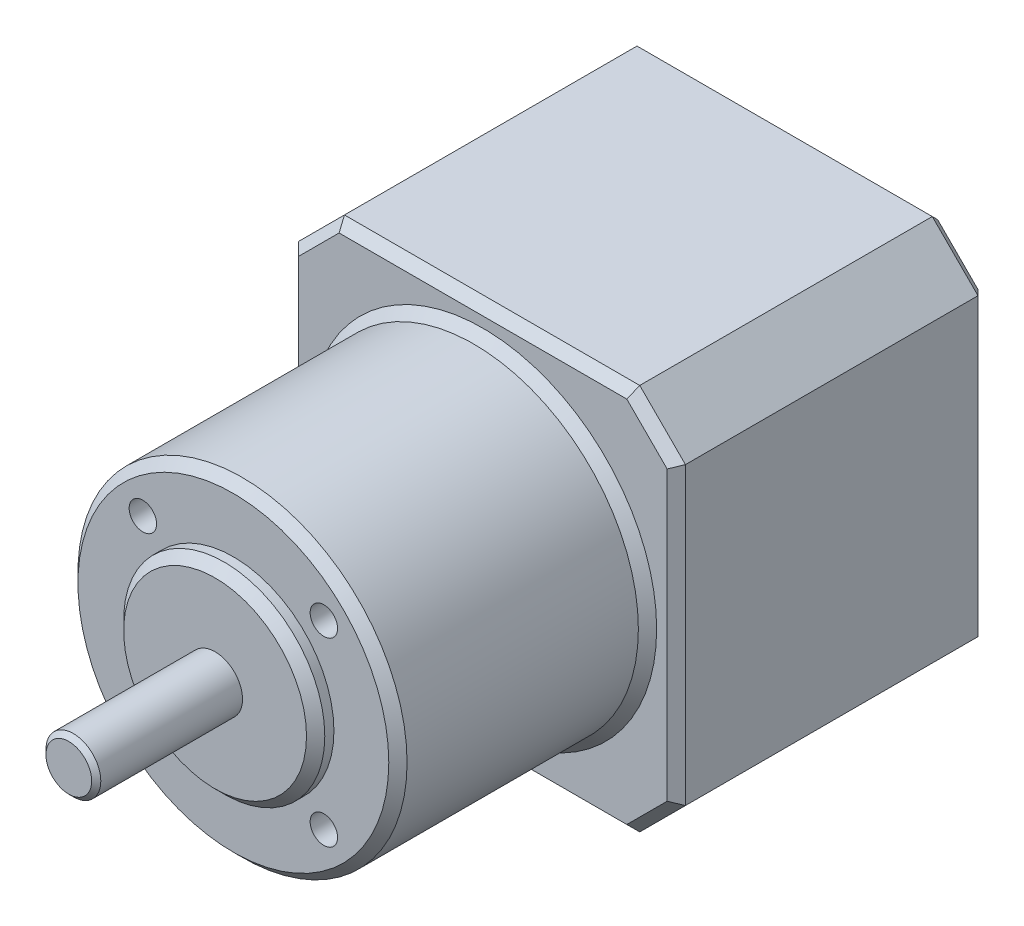
from build123d import *

# Parameters (mm, degrees)
SKETCH1_W           = 42.3
SKETCH1_H           = 42.3
BOSS_EXTRUDE1_DEPTH = 34
CHAMFER1_SIZE       = 5
SKETCH2_R           = 18
BOSS_EXTRUDE2_DEPTH = 27.3
SKETCH3_R           = 11
BOSS_EXTRUDE3_DEPTH = 2
SKETCH4_R           = 3
BOSS_EXTRUDE4_DEPTH = 16
CHAMFER2_SIZE       = 1
CHAMFER3_SIZE       = 0.5
SKETCH5_R           = 1.5
CUT_EXTRUDE1_DEPTH  = 5


with BuildPart() as part:
    # Sketch1 → Boss-Extrude1 (new body)
    with BuildSketch(Plane.XY):
        Rectangle(SKETCH1_W, SKETCH1_H)
    extrude(amount=BOSS_EXTRUDE1_DEPTH)

    # Chamfer1
    chamfer1_edges = [part.edges().sort_by_distance(p)[0] for p in [
        (21.15, -21.15, 17),
        (-21.15, -21.15, 17),
        (-21.15, 21.15, 17),
        (21.15, 21.15, 17),
    ]]
    chamfer(chamfer1_edges, length=CHAMFER1_SIZE)

    # Sketch2 → Boss-Extrude2 (add)
    with BuildSketch(Plane.XY.offset(34)):
        Circle(SKETCH2_R)
    extrude(amount=BOSS_EXTRUDE2_DEPTH)

    # Sketch3 → Boss-Extrude3 (add)
    with BuildSketch(Plane.XY.offset(61.3)):
        Circle(SKETCH3_R)
    extrude(amount=BOSS_EXTRUDE3_DEPTH)

    # Sketch4 → Boss-Extrude4 (add)
    with BuildSketch(Plane.XY.offset(63.3)):
        Circle(SKETCH4_R)
    extrude(amount=BOSS_EXTRUDE4_DEPTH)

    # Chamfer2
    chamfer2_edges = [part.edges().sort_by_distance(p)[0] for p in [
        (0, -21.15, 0),
        (0, -21.15, 34),
        (21.15, 0, 0),
        (-21.15, 0, 0),
        (0, 21.15, 0),
        (18.65, 18.65, 0),
        (18.65, -18.65, 0),
        (-18.65, 18.65, 0),
        (-18.65, -18.65, 0),
        (-21.15, 0, 34),
        (21.15, 0, 34),
        (0, 21.15, 34),
        (18.65, 18.65, 34),
        (18.65, -18.65, 34),
        (-18.65, 18.65, 34),
        (-18.65, -18.65, 34),
        (-18, 0, 34),
        (-18, 0, 61.3),
        (-11, 0, 63.3),
    ]]
    chamfer(chamfer2_edges, length=CHAMFER2_SIZE)

    # Chamfer3
    chamfer3_edges = [part.edges().sort_by_distance(p)[0] for p in [
        (-3, 0, 79.3),
    ]]
    chamfer(chamfer3_edges, length=CHAMFER3_SIZE)

    # Sketch5 → Cut-Extrude1 (cut)
    with BuildSketch(Plane.XY.offset(61.3)):
        with Locations((9.899494937, 9.899494937)):
            Circle(SKETCH5_R)
        with Locations((9.899494937, -9.899494937)):
            Circle(SKETCH5_R)
        with Locations((-9.899494937, -9.899494937)):
            Circle(SKETCH5_R)
        with Locations((-9.899494937, 9.899494937)):
            Circle(SKETCH5_R)
    extrude(amount=-CUT_EXTRUDE1_DEPTH, mode=Mode.SUBTRACT)


solid = part.part
